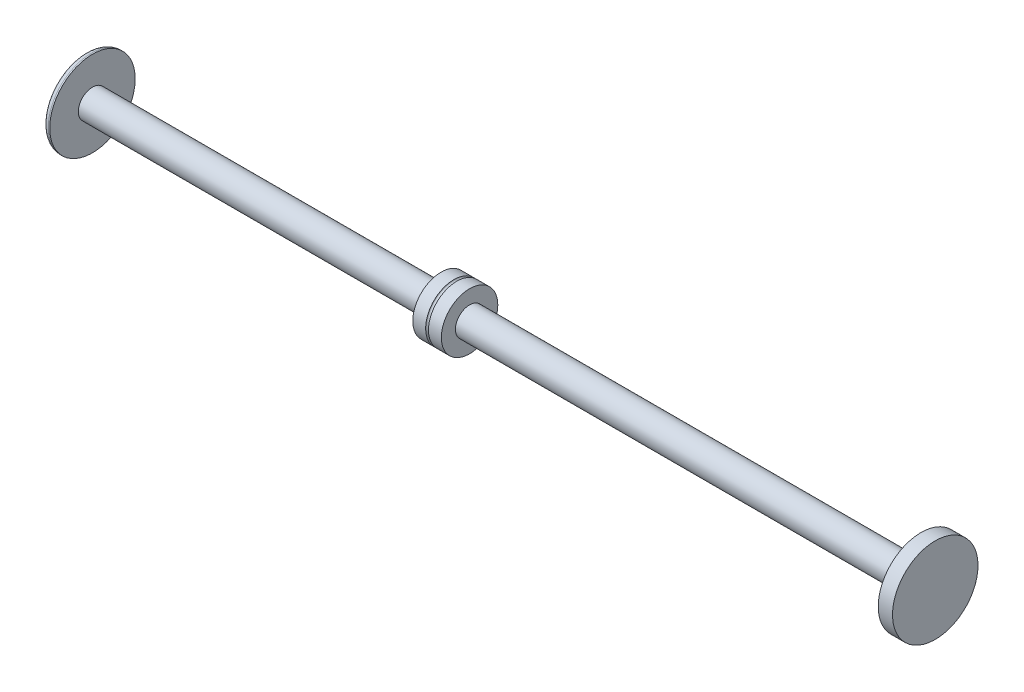
from build123d import *

# Parameters (mm, degrees)
SKETCH3_R = 0.635


with BuildPart() as part:
    # Sketch2 → Revolve1 (revolve)
    with BuildSketch(Plane(origin=(25.4, 0, -190.199803954), x_dir=(1, 0, 0), z_dir=(0, 0, 1))):
        with BuildLine():
            Line((-10.16, 1439.086510137), (114.3, 1439.086510137))
            Line((114.3, 1439.086510137), (190.5, 1439.086510137))
            Line((190.5, 1439.086510137), (190.5, 1451.786510137))
            Line((190.5, 1451.786510137), (196.85, 1451.786510137))
            Line((196.85, 1451.786510137), (196.85, 1432.787310137))
            Line((196.85, 1432.787310137), (-180.975, 1432.787310137))
            Line((-180.975, 1432.787310137), (-180.975, 1449.246510137))
            ThreePointArc((-180.975, 1449.246510137), (-180.231051224, 1451.042561361), (-178.435, 1451.786510137))
            Line((-178.435, 1451.786510137), (-177.8, 1451.786510137))
            Line((-177.8, 1451.786510137), (-177.8, 1439.086510137))
            Line((-177.8, 1439.086510137), (-101.6, 1439.086510137))
            Line((-101.6, 1439.086510137), (-91.44, 1439.086510137))
            Line((-91.44, 1439.086510137), (-22.86, 1439.086510137))
            Line((-22.86, 1439.086510137), (-22.86, 1445.334910137))
            Line((-22.86, 1445.334910137), (-10.16, 1445.334910137))
            Line((-10.16, 1445.334910137), (-10.16, 1439.086510137))
        make_face()
    revolve(axis=Axis((25.4, 1432.787310137, -190.199803954), (-1, 0, 0)))

    # Sketch3 → Cut-Revolve1 (revolve, cut)
    with BuildSketch(Plane(origin=(25.4, 0, -190.199803954), x_dir=(1, 0, 0), z_dir=(0, 0, 1))):
        with Locations((-16.51, 1445.334910137)):
            Circle(SKETCH3_R)
    revolve(axis=Axis((2.54, 1432.787310137, -190.199803954), (1, 0, 0)), mode=Mode.SUBTRACT)


solid = part.part
